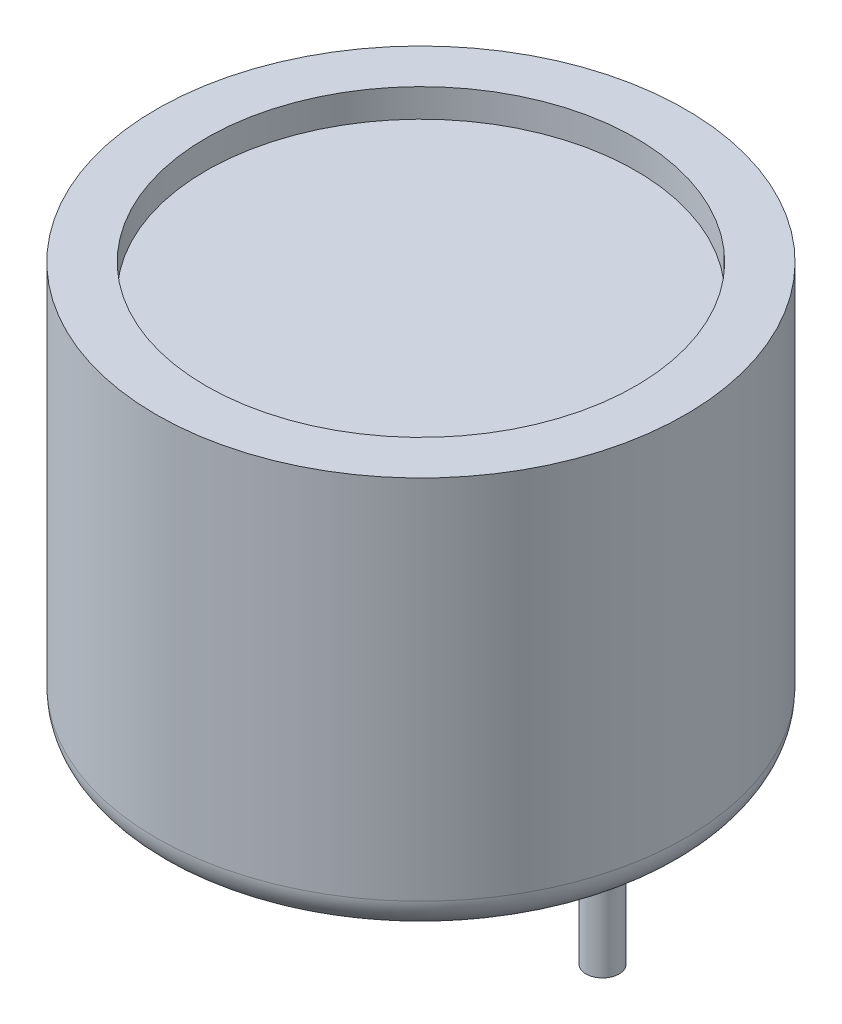
from build123d import *

# Parameters (mm, degrees)
SKETCH1_R           = 7.975
BOSS_EXTRUDE1_DEPTH = 12.05
FILLET1_R           = 1
SKETCH3_R           = 6.975
CUT_EXTRUDE1_DEPTH  = 0.75
SKETCH4_R           = 0.5
BOSS_EXTRUDE2_DEPTH = 4.3
SKETCH5_R           = 6.475
CUT_EXTRUDE2_DEPTH  = 0.85


with BuildPart() as part:
    # Sketch1 → Boss-Extrude1 (new body)
    with BuildSketch(Plane(origin=(0, 0, 0), x_dir=(1, 0, 0), z_dir=(0, 1, 0))):
        Circle(SKETCH1_R)
    extrude(amount=BOSS_EXTRUDE1_DEPTH)

    # Fillet1
    fillet1_edges = [part.edges().sort_by_distance(p)[0] for p in [
        (-7.975, 0, 0),
    ]]
    fillet(fillet1_edges, radius=FILLET1_R)

    # Sketch3 → Cut-Extrude1 (cut)
    with BuildSketch(Plane.XZ):
        Circle(SKETCH3_R)
    extrude(amount=-CUT_EXTRUDE1_DEPTH, mode=Mode.SUBTRACT)

    # Sketch4 → Boss-Extrude2 (add)
    with BuildSketch(Plane.XZ.offset(-0.75)):
        with Locations((-5.475, 0)):
            Circle(SKETCH4_R)
        with Locations((5.475, 0)):
            Circle(SKETCH4_R)
    extrude(amount=BOSS_EXTRUDE2_DEPTH)

    # Sketch5 → Cut-Extrude2 (cut)
    with BuildSketch(Plane(origin=(0, 12.05, 0), x_dir=(1, 0, 0), z_dir=(0, 1, 0))):
        Circle(SKETCH5_R)
    extrude(amount=-CUT_EXTRUDE2_DEPTH, mode=Mode.SUBTRACT)


solid = part.part
